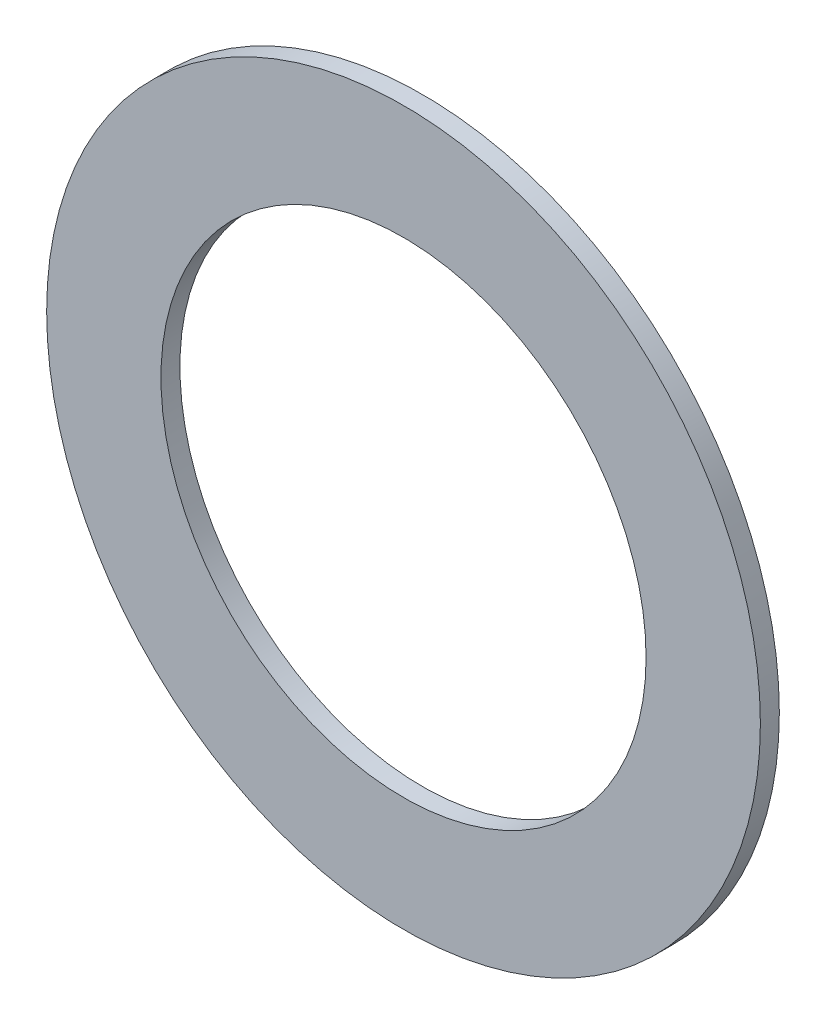
from build123d import *

# Parameters (mm, degrees)
SKETCH1_R           = 128
SKETCH1_R_2         = 87
BOSS_EXTRUDE2_DEPTH = 6.8


with BuildPart() as part:
    # Sketch1 → Boss-Extrude2 (new body)
    with BuildSketch(Plane.XY):
        Circle(SKETCH1_R)
        Circle(SKETCH1_R_2, mode=Mode.SUBTRACT)
    extrude(amount=BOSS_EXTRUDE2_DEPTH)


solid = part.part
